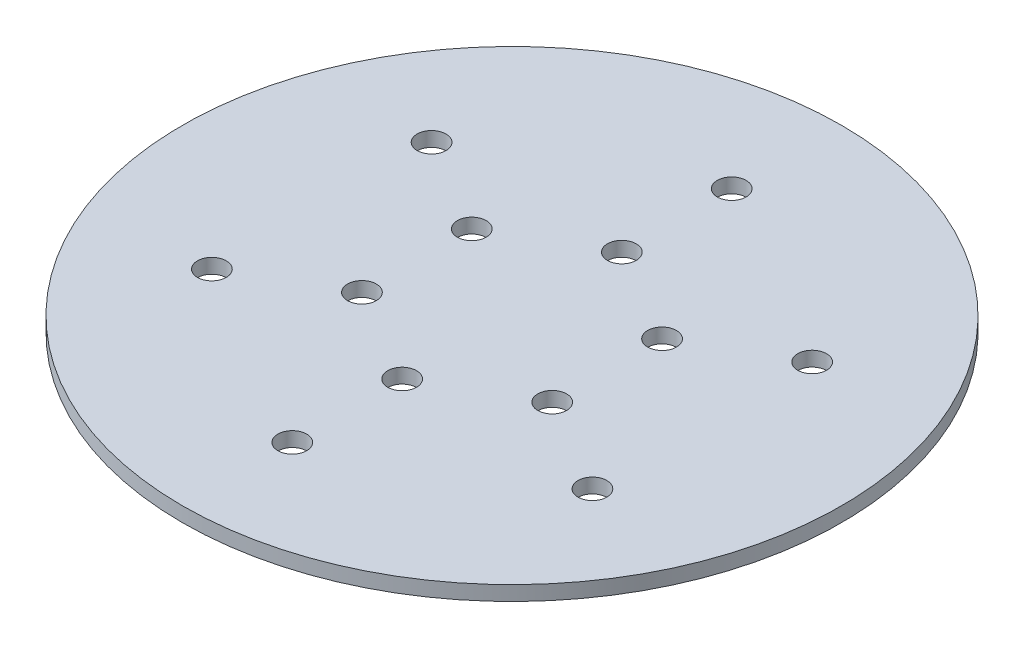
from build123d import *

# Parameters (mm, degrees)
SKETCH2_R           = 114.3
SKETCH2_R_2         = 5
BOSS_EXTRUDE1_DEPTH = 5.08


with BuildPart() as part:
    # Sketch2 → Boss-Extrude1 (new body)
    with BuildSketch(Plane(origin=(0, 0, 0), x_dir=(1, 0, 0), z_dir=(0, 1, 0))):
        Circle(SKETCH2_R)
        with Locations((0, 38.1)):
            Circle(SKETCH2_R_2, mode=Mode.SUBTRACT)
        with Locations((0, 76.2)):
            Circle(SKETCH2_R_2, mode=Mode.SUBTRACT)
        with Locations((65.991135768, 38.1)):
            Circle(SKETCH2_R_2, mode=Mode.SUBTRACT)
        with Locations((32.995567884, 19.05)):
            Circle(SKETCH2_R_2, mode=Mode.SUBTRACT)
        with Locations((65.991135768, -38.1)):
            Circle(SKETCH2_R_2, mode=Mode.SUBTRACT)
        with Locations((32.995567884, -19.05)):
            Circle(SKETCH2_R_2, mode=Mode.SUBTRACT)
        with Locations((0, -76.2)):
            Circle(SKETCH2_R_2, mode=Mode.SUBTRACT)
        with Locations((0, -38.1)):
            Circle(SKETCH2_R_2, mode=Mode.SUBTRACT)
        with Locations((-65.991135768, -38.1)):
            Circle(SKETCH2_R_2, mode=Mode.SUBTRACT)
        with Locations((-32.995567884, -19.05)):
            Circle(SKETCH2_R_2, mode=Mode.SUBTRACT)
        with Locations((-65.991135768, 38.1)):
            Circle(SKETCH2_R_2, mode=Mode.SUBTRACT)
        with Locations((-32.995567884, 19.05)):
            Circle(SKETCH2_R_2, mode=Mode.SUBTRACT)
    extrude(amount=BOSS_EXTRUDE1_DEPTH)


solid = part.part
